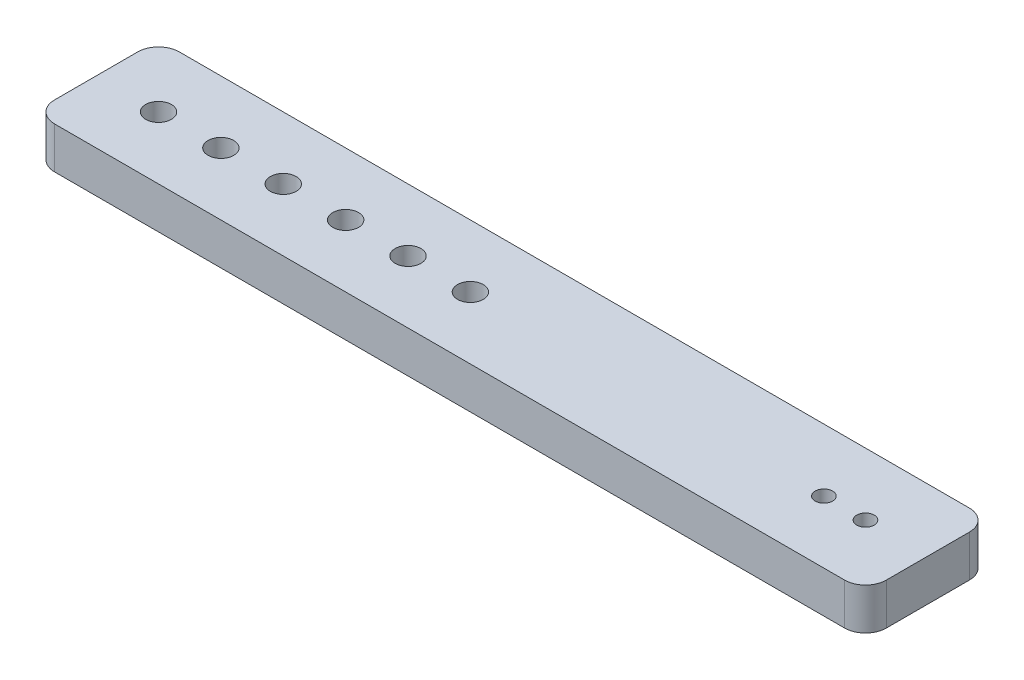
from build123d import *

# Parameters (mm, degrees)
SKETCH1_W           = 200
SKETCH1_H           = 30
BOSS_EXTRUDE1_DEPTH = 10
SKETCH2_R           = 2.1
CUT_EXTRUDE1_DEPTH  = 11
SKETCH3_R           = 3.1
CUT_EXTRUDE2_DEPTH  = 11
LPATTERN1_COUNT     = 6
LPATTERN1_PITCH     = 15
FILLET1_R           = 5


with BuildPart() as part:
    # Sketch1 → Boss-Extrude1 (new body)
    with BuildSketch(Plane(origin=(0, 0, 0), x_dir=(1, 0, 0), z_dir=(0, 1, 0))):
        Rectangle(SKETCH1_W, SKETCH1_H)
    extrude(amount=BOSS_EXTRUDE1_DEPTH)

    # Sketch2 → Cut-Extrude1 (cut, through all)
    with BuildSketch(Plane(origin=(0, 10, 0), x_dir=(1, 0, 0), z_dir=(0, 1, 0))):
        with Locations((85, 0)):
            Circle(SKETCH2_R)
        with Locations((75, 0)):
            Circle(SKETCH2_R)
    extrude(amount=-CUT_EXTRUDE1_DEPTH, mode=Mode.SUBTRACT)

    # Sketch3 → Cut-Extrude2 (cut, through all)
    with BuildSketch(Plane(origin=(0, 10, 0), x_dir=(1, 0, 0), z_dir=(0, 1, 0))):
        with Locations((-85, 0)):
            Circle(SKETCH3_R)
    cut_extrude2 = extrude(amount=-CUT_EXTRUDE2_DEPTH, mode=Mode.SUBTRACT)

    # LPattern1: Cut-Extrude2 ×6
    with Locations(*[(i * LPATTERN1_PITCH, 0, 0) for i in range(1, LPATTERN1_COUNT)]):
        add(cut_extrude2, mode=Mode.SUBTRACT)

    # Fillet1
    fillet1_edges = [part.edges().sort_by_distance(p)[0] for p in [
        (-100, 5, -15),
        (100, 5, -15),
        (100, 5, 15),
        (-100, 5, 15),
    ]]
    fillet(fillet1_edges, radius=FILLET1_R)


solid = part.part
